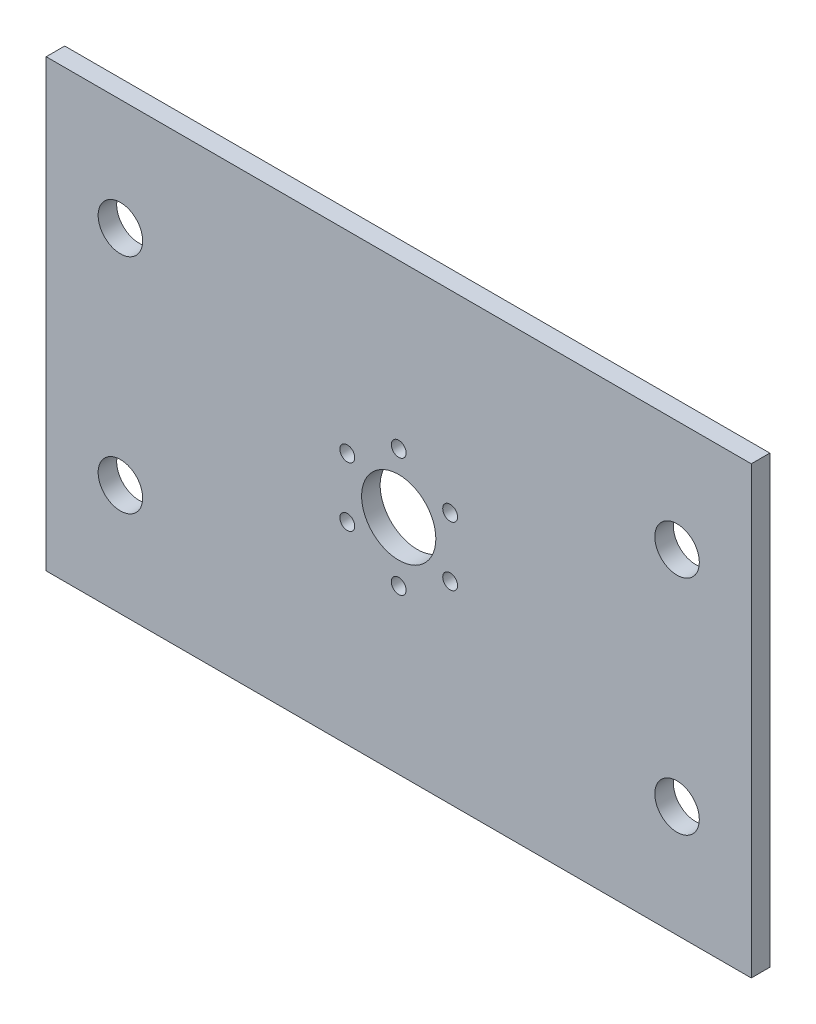
from build123d import *

# Parameters (mm, degrees)
SKETCH1_W           = 190
SKETCH1_H           = 120
SKETCH1_R           = 6
SKETCH1_R_2         = 10
SKETCH1_R_3         = 2
BOSS_EXTRUDE1_DEPTH = 5


with BuildPart() as part:
    # Sketch1 → Boss-Extrude1 (new body)
    with BuildSketch(Plane.XY):
        Rectangle(SKETCH1_W, SKETCH1_H)
        with Locations((-75, 30)):
            Circle(SKETCH1_R, mode=Mode.SUBTRACT)
        with Locations((75, 30)):
            Circle(SKETCH1_R, mode=Mode.SUBTRACT)
        with Locations((75, -30)):
            Circle(SKETCH1_R, mode=Mode.SUBTRACT)
        with Locations((-75, -30)):
            Circle(SKETCH1_R, mode=Mode.SUBTRACT)
        Circle(SKETCH1_R_2, mode=Mode.SUBTRACT)
        with Locations((0, 16)):
            Circle(SKETCH1_R_3, mode=Mode.SUBTRACT)
        with Locations((13.856406461, 8)):
            Circle(SKETCH1_R_3, mode=Mode.SUBTRACT)
        with Locations((13.856406461, -8)):
            Circle(SKETCH1_R_3, mode=Mode.SUBTRACT)
        with Locations((0, -16)):
            Circle(SKETCH1_R_3, mode=Mode.SUBTRACT)
        with Locations((-13.856406461, -8)):
            Circle(SKETCH1_R_3, mode=Mode.SUBTRACT)
        with Locations((-13.856406461, 8)):
            Circle(SKETCH1_R_3, mode=Mode.SUBTRACT)
    extrude(amount=BOSS_EXTRUDE1_DEPTH)


solid = part.part
